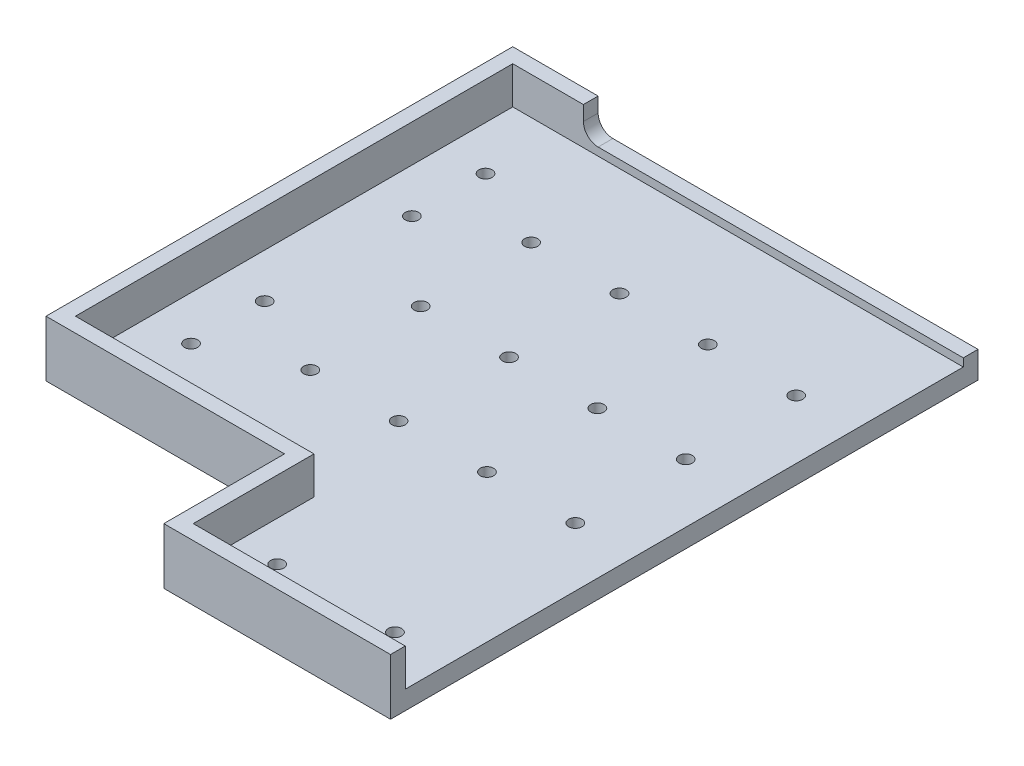
from build123d import *

# Parameters (mm, degrees)
SKETCH1_W                = 158
SKETCH1_H                = 199.5
BOSS_EXTRUDE1_DEPTH      = 6.35
SKETCH2_W                = 81
SKETCH2_H                = 41
CUT_EXTRUDE1_DEPTH       = 7.35
BOSS_EXTRUDE2_DEPTH      = 12.7
M4_CLEARANCE_HOLE1_D     = 4.5
M4_CLEARANCE_HOLE1_DEPTH = 6.35
CUT_EXTRUDE2_REACH       = 201.5
SKETCH7_W                = 129
SKETCH7_H                = 10
FILLET1_R                = 5
M4_CLEARANCE_HOLE2_D     = 4.5
M4_CLEARANCE_HOLE2_DEPTH = 6.35
LPATTERN1_COUNT          = 4
LPATTERN1_PITCH          = 30
LPATTERN1_COUNT_DIR2     = 3
LPATTERN1_PITCH_DIR2     = 37.5


with BuildPart() as part:
    # Sketch1 → Boss-Extrude1 (new body)
    with BuildSketch(Plane(origin=(0, 0, 0), x_dir=(1, 0, 0), z_dir=(0, 1, 0))):
        with Locations((79, -99.75)):
            Rectangle(SKETCH1_W, SKETCH1_H)
    extrude(amount=BOSS_EXTRUDE1_DEPTH)

    # Sketch2 → Cut-Extrude1 (cut, through all)
    with BuildSketch(Plane(origin=(0, 6.35, 0), x_dir=(1, 0, 0), z_dir=(0, 1, 0))):
        with Locations((40.5, -179)):
            Rectangle(SKETCH2_W, SKETCH2_H)
    extrude(amount=-CUT_EXTRUDE1_DEPTH, mode=Mode.SUBTRACT)

    # Sketch3 → Boss-Extrude2 (add)
    with BuildSketch(Plane(origin=(0, 6.35, 0), x_dir=(1, 0, 0), z_dir=(0, 1, 0))):
        Polygon((158, 0), (158, -5), (5, -5), (5, -153.5), (86, -153.5), (86, -194.5), (158, -194.5), (158, -199.5), (86, -199.5), (81, -199.5), (81, -158.5), (0, -158.5), (0, 0), align=None)
    extrude(amount=BOSS_EXTRUDE2_DEPTH)

    # M4 Clearance Hole1
    with Locations(Plane.XZ):
        with Locations((20, 54.25), (99.5, 179.5), (139.5, 179.5), (20, 129.25), (20, 104.25), (20, 29.25)):
            Hole(M4_CLEARANCE_HOLE1_D / 2, depth=M4_CLEARANCE_HOLE1_DEPTH)

    # Sketch7 → Cut-Extrude2 (cut, up to next)
    with BuildSketch(Plane(origin=(0, 0, 0), x_dir=(-1, 0, 0), z_dir=(0, 0, -1)), mode=Mode.PRIVATE) as cut_extrude2_sk1:
        with Locations((-93.5, 14.05)):
            Rectangle(SKETCH7_W, SKETCH7_H)
    cut_extrude2_tool1 = extrude(cut_extrude2_sk1.sketch, amount=-CUT_EXTRUDE2_REACH, mode=Mode.PRIVATE) & part.part
    add(cut_extrude2_tool1.solids().sort_by_distance((93.5, 14.05, 0))[0], mode=Mode.SUBTRACT)

    # Fillet1
    fillet1_edges = [part.edges().sort_by_distance(p)[0] for p in [
        (29, 9.05, 2.5),
    ]]
    fillet(fillet1_edges, radius=FILLET1_R)

    # M4 Clearance Hole2
    with Locations(Plane(origin=(0, 6.35, 0), x_dir=(1, 0, 0), z_dir=(0, 1, 0))):
        with Locations((138, -116.75)):
            m4_clearance_hole2 = Hole(M4_CLEARANCE_HOLE2_D / 2, depth=M4_CLEARANCE_HOLE2_DEPTH)

    # LPattern1: M4 Clearance Hole2 4 × 3
    with Locations(*[(-i * LPATTERN1_PITCH, 0, -j * LPATTERN1_PITCH_DIR2) for i in range(LPATTERN1_COUNT) for j in range(LPATTERN1_COUNT_DIR2) if (i, j) != (0, 0)]):
        add(m4_clearance_hole2, mode=Mode.SUBTRACT)


solid = part.part
